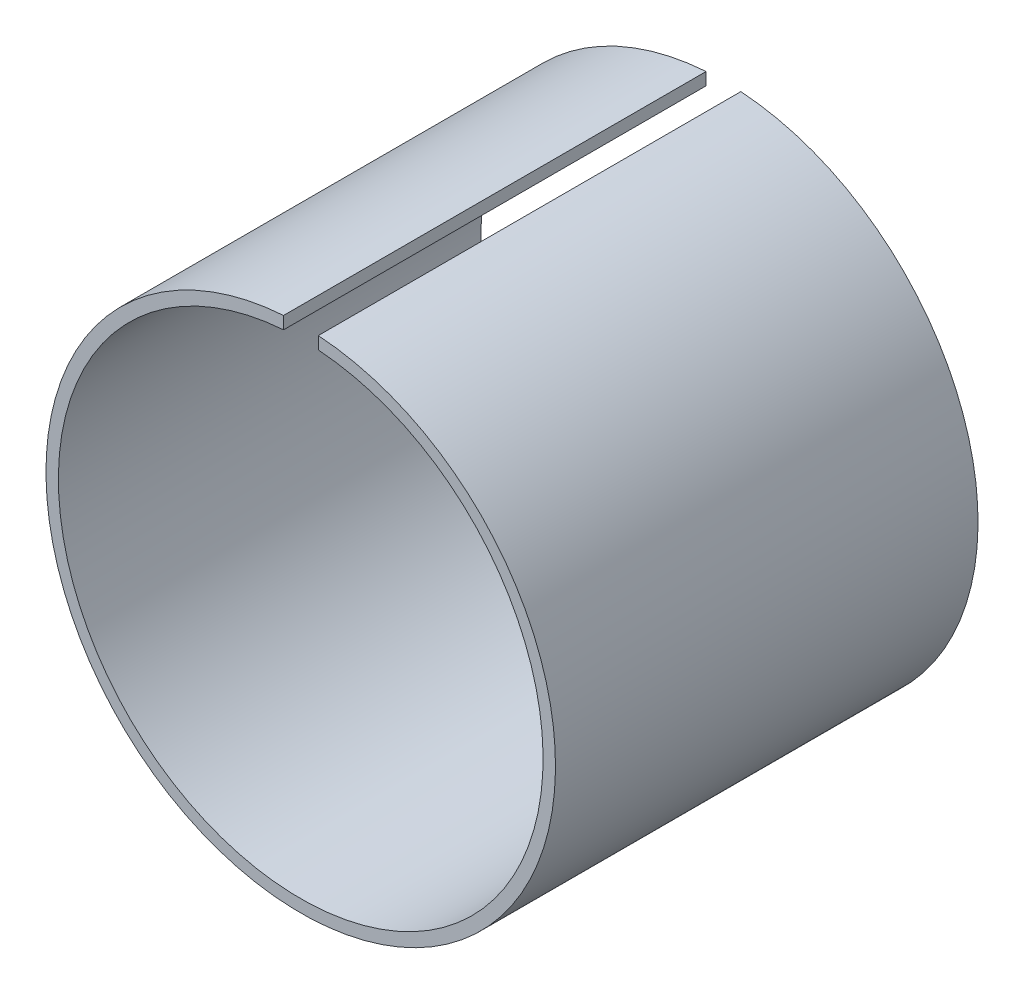
from build123d import *

# Parameters (mm, degrees)
SKETCH1_R           = 20.5
SKETCH1_R_2         = 19.5
BOSS_EXTRUDE1_DEPTH = 34
SKETCH2_W           = 2.79800491
SKETCH2_H           = 1.698963444
CUT_EXTRUDE1_DEPTH  = 35


with BuildPart() as part:
    # Sketch1 → Boss-Extrude1 (new body)
    with BuildSketch(Plane.XY):
        Circle(SKETCH1_R)
        Circle(SKETCH1_R_2, mode=Mode.SUBTRACT)
    extrude(amount=BOSS_EXTRUDE1_DEPTH)

    # Sketch2 → Cut-Extrude1 (cut, through all)
    with BuildSketch(Plane.XY.offset(34)):
        with Locations((0.015441627, 20.064895184)):
            Rectangle(SKETCH2_W, SKETCH2_H)
    extrude(amount=-CUT_EXTRUDE1_DEPTH, mode=Mode.SUBTRACT)


solid = part.part
